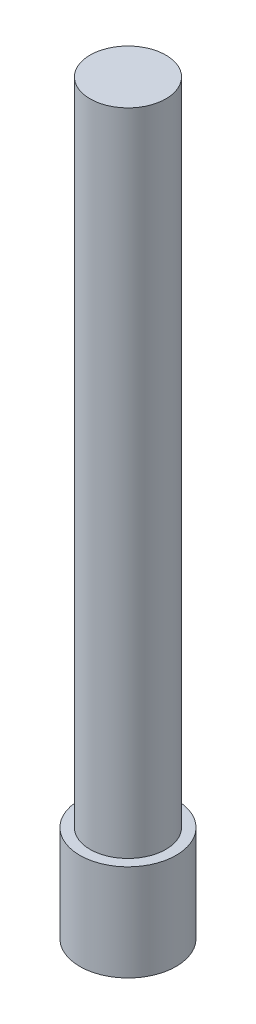
from build123d import *

# Parameters (mm, degrees)
SKETCH1_R           = 2
SKETCH1_R_2         = 1.025
BOSS_EXTRUDE1_DEPTH = 3
SKETCH2_R           = 2
BOSS_EXTRUDE2_DEPTH = 1
SKETCH3_R           = 1.575
BOSS_EXTRUDE3_DEPTH = 27


with BuildPart() as part:
    # Sketch1 → Boss-Extrude1 (new body)
    with BuildSketch(Plane(origin=(0, 0, 0), x_dir=(1, 0, 0), z_dir=(0, 1, 0))):
        Circle(SKETCH1_R)
        Circle(SKETCH1_R_2, mode=Mode.SUBTRACT)
    extrude(amount=BOSS_EXTRUDE1_DEPTH)

    # Sketch2 → Boss-Extrude2 (add)
    with BuildSketch(Plane(origin=(0, 3, 0), x_dir=(1, 0, 0), z_dir=(0, 1, 0))):
        Circle(SKETCH2_R)
    extrude(amount=BOSS_EXTRUDE2_DEPTH)

    # Sketch3 → Boss-Extrude3 (add)
    with BuildSketch(Plane(origin=(0, 4, 0), x_dir=(1, 0, 0), z_dir=(0, 1, 0))):
        Circle(SKETCH3_R)
    extrude(amount=BOSS_EXTRUDE3_DEPTH)


solid = part.part
